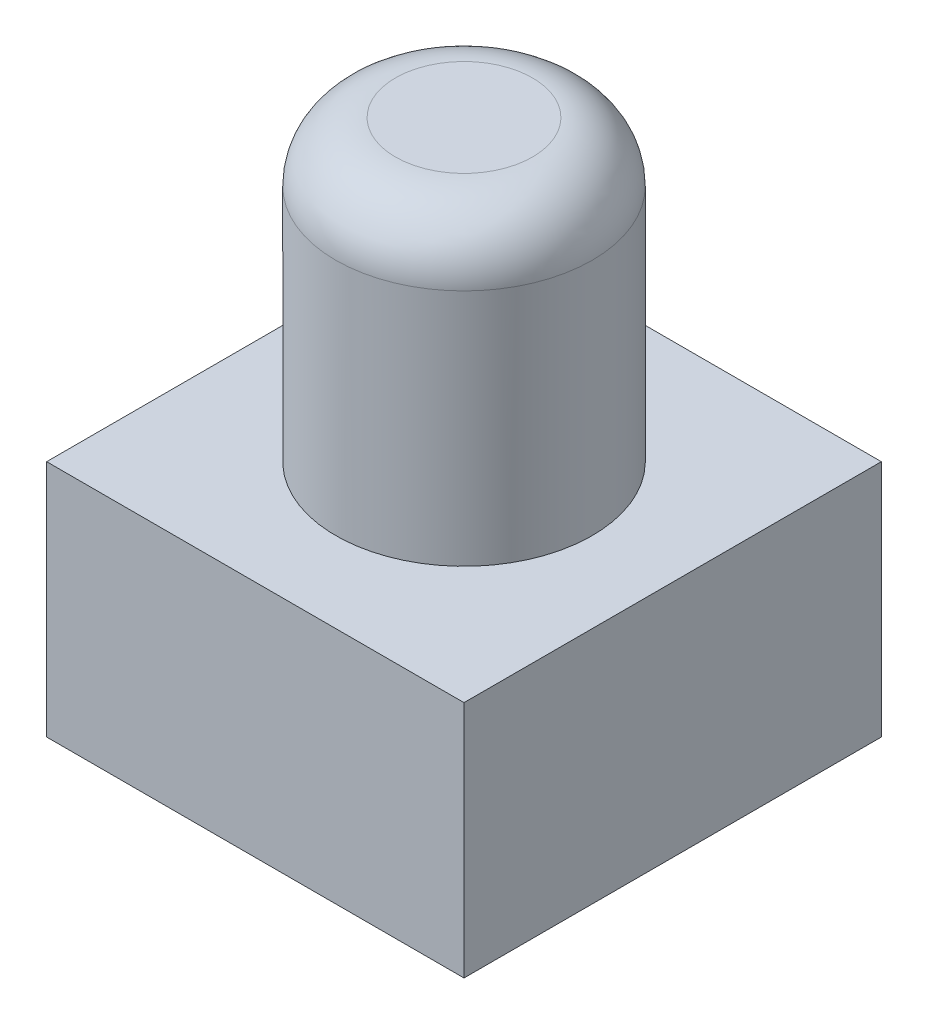
from build123d import *

# Parameters (mm, degrees)
SKETCH1_R                = 2.15
BOSS_EXTRUDE1_DEPTH      = 7
BOSS_EXTRUDE2_DEPTH      = 2
BOSS_EXTRUDE2_DEPTH_BACK = 2
SKETCH3_W                = 7
SKETCH3_H                = 7
FILLET1_R                = 1
SKETCH5_W                = 5.5
SKETCH5_H                = 5.5
CUT_EXTRUDE1_DEPTH       = 2


with BuildPart() as part:
    # Sketch1 → Boss-Extrude1 (new body)
    with BuildSketch(Plane(origin=(0, 0, 0), x_dir=(1, 0, 0), z_dir=(0, 1, 0))):
        Circle(SKETCH1_R)
    extrude(amount=BOSS_EXTRUDE1_DEPTH)

    # Sketch3 → Boss-Extrude2 (add, two sides: drawn at the far end of the back side and taken through both)
    with BuildSketch(Plane.XZ.offset(-BOSS_EXTRUDE2_DEPTH_BACK)):
        Rectangle(SKETCH3_W, SKETCH3_H)
    extrude(amount=BOSS_EXTRUDE2_DEPTH + BOSS_EXTRUDE2_DEPTH_BACK)

    # Fillet1
    fillet1_edges = [part.edges().sort_by_distance(p)[0] for p in [
        (-2.15, 7, 0),
    ]]
    fillet(fillet1_edges, radius=FILLET1_R)

    # Sketch5 → Cut-Extrude1 (cut)
    with BuildSketch(Plane.XZ.offset(2)):
        Rectangle(SKETCH5_W, SKETCH5_H)
    extrude(amount=-CUT_EXTRUDE1_DEPTH, mode=Mode.SUBTRACT)


solid = part.part
